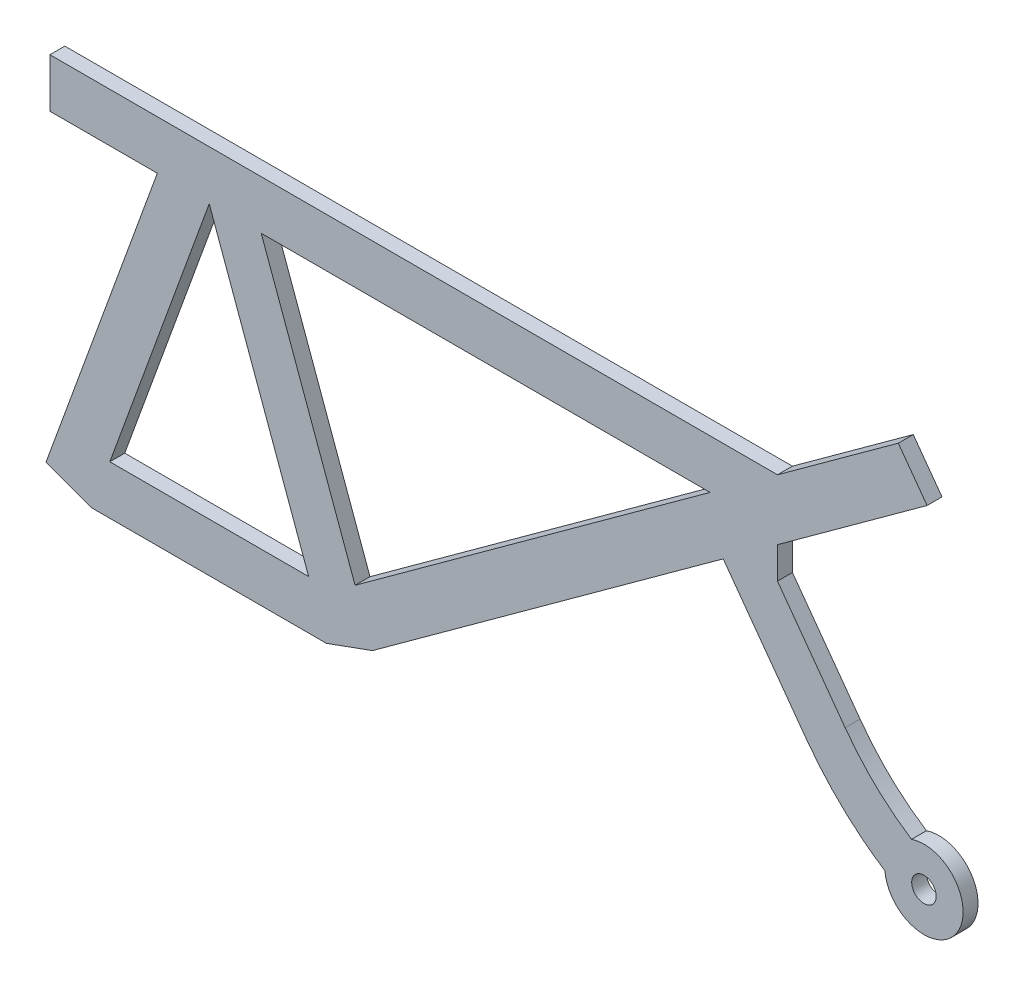
from build123d import *

# Parameters (mm, degrees)
SKETCH1_R           = 2.5
BOSS_EXTRUDE1_DEPTH = 3.048


with BuildPart() as part:
    # Sketch1 → Boss-Extrude1 (new body)
    with BuildSketch(Plane.XY):
        with BuildLine():
            Line((0, 0), (71.622808257, 52.037016174))
            Line((71.622808257, 52.037016174), (88.501669832, 28.805256264))
            add(Edge.make_bspline(
                [(88.501669832, 28.805256264), (92.966978859, 22.659285651), (98.410551954, 17.410609678), (104.704030367, 13.341863973)],
                knots=[0.5, 0.5, 0.5, 0.5, 0.915853648, 0.915853648, 0.915853648, 0.915853648], degree=3))
            Line((104.704030367, 13.341863973), (104.658496812, 13.271443843))
            ThreePointArc((104.658496812, 13.271443843), (119.335898328, 9.736398283), (110.087731709, 21.669297201))
            add(Edge.make_bspline(
                [(96.52401812, 34.63383347), (97.463660016, 33.340527353), (99.467318776, 30.820691276), (103.81543362, 26.262690934), (107.476268967, 23.357612806), (110.087731709, 21.669297201)],
                knots=[0.5, 0.5, 0.5, 0.5, 0.603963412, 0.707926824, 0.915853648, 0.915853648, 0.915853648, 0.915853648], degree=3))
            Line((96.52401812, 34.63383347), (82.711847228, 53.644655768))
            Line((82.711847228, 53.644655768), (82.711847228, 60.093674581))
            Line((82.711847228, 60.093674581), (113.262379212, 82.289935321))
            Line((113.262379212, 82.289935321), (107.38452669, 90.380105265))
            Line((107.38452669, 90.380105265), (82.711847228, 72.454354356))
            Line((82.711847228, 72.454354356), (-5.877852523, 72.454354356))
            Line((-5.877852523, 72.454354356), (-65.877852523, 72.454354356))
            Line((-65.877852523, 72.454354356), (-65.877852523, 62.454354356))
            Line((-65.877852523, 62.454354356), (-43.945146495, 62.454354356))
            Line((-43.945146495, 62.454354356), (-66.676672481, 0))
            Line((-66.676672481, 0), (-57.279746273, -3.420201433))
            Line((-57.279746273, -3.420201433), (-9.396926208, -3.420201433))
            Line((-9.396926208, -3.420201433), (0, 0))
        make_face()
        with Locations((112.61759651, 14.07979857)):
            Circle(SKETCH1_R, mode=Mode.SUBTRACT)
        Polygon((-3.558033622, 9.775617033), (68.948028023, 62.454354356), (-5.877852523, 62.454354356), (-22.731525986, 62.454354356), align=None, mode=Mode.SUBTRACT)
        Polygon((-13.036628551, 6.579798567), (-33.338336241, 62.358282022), (-53.640043931, 6.579798567), align=None, mode=Mode.SUBTRACT)
    extrude(amount=BOSS_EXTRUDE1_DEPTH)


solid = part.part
